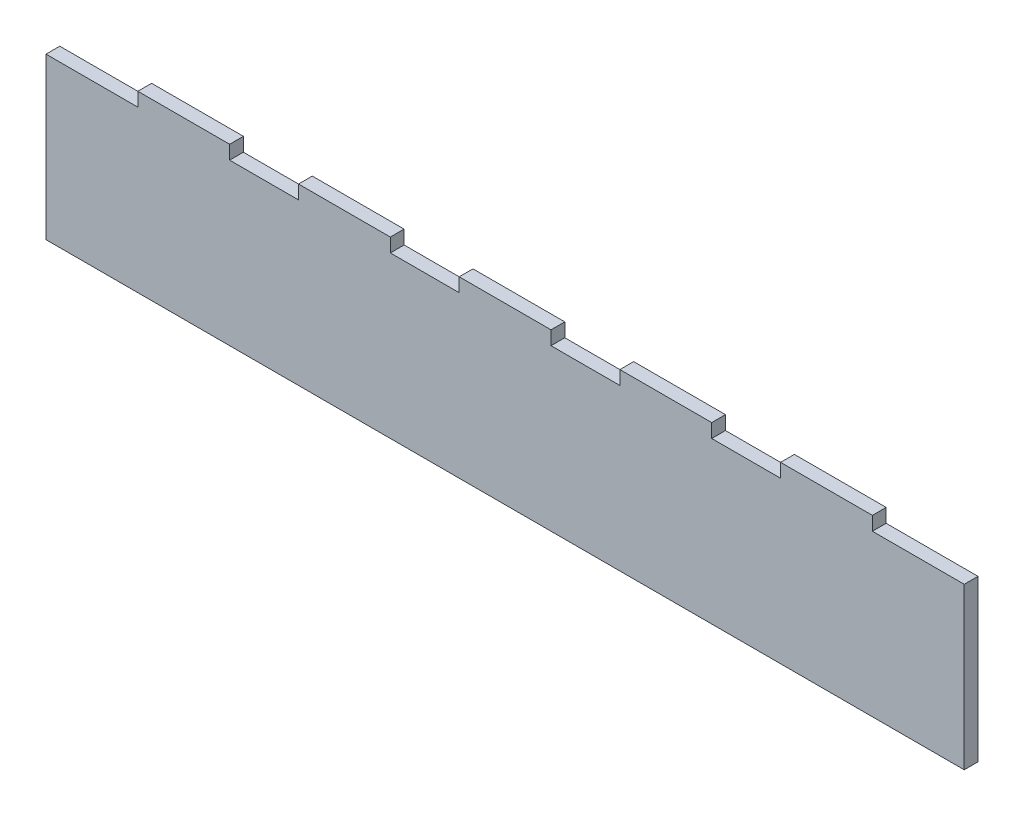
from build123d import *

# Parameters (mm, degrees)
BOSS_EXTRUDE1_DEPTH = 3


with BuildPart() as part:
    # Sketch1 → Boss-Extrude1 (new body)
    with BuildSketch(Plane(origin=(0, 0, 0), x_dir=(1, 0, 0), z_dir=(0, 0, -1))):
        Polygon((40, 0), (55, 0), (55, -3), (75, -3), (75, 0), (90, 0), (90, -3), (110, -3), (110, 0), (125, 0), (125, -3), (145, -3), (145, 0), (160, 0), (160, -3), (180, -3), (180, 0), (200, 0), (200, 35), (0, 35), (0, 0), (20, 0), (20, -3), (40, -3), align=None)
    extrude(amount=BOSS_EXTRUDE1_DEPTH)


solid = part.part
